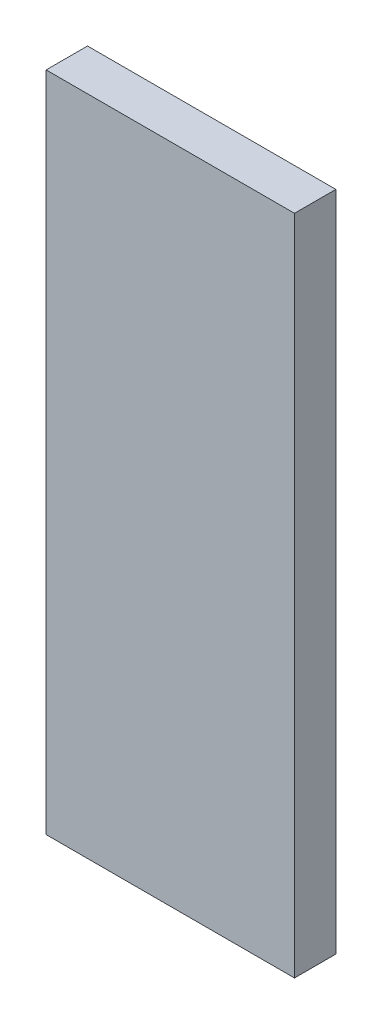
from build123d import *

# Parameters (mm, degrees)
SKETCH1_W           = 38.1
SKETCH1_H           = 6.35
BOSS_EXTRUDE1_DEPTH = 101.6


with BuildPart() as part:
    # Sketch1 → Boss-Extrude1 (new body)
    with BuildSketch(Plane(origin=(0, 0, 0), x_dir=(1, 0, 0), z_dir=(0, 1, 0))):
        with Locations((-19.05, -3.175)):
            Rectangle(SKETCH1_W, SKETCH1_H)
    extrude(amount=BOSS_EXTRUDE1_DEPTH)


solid = part.part
